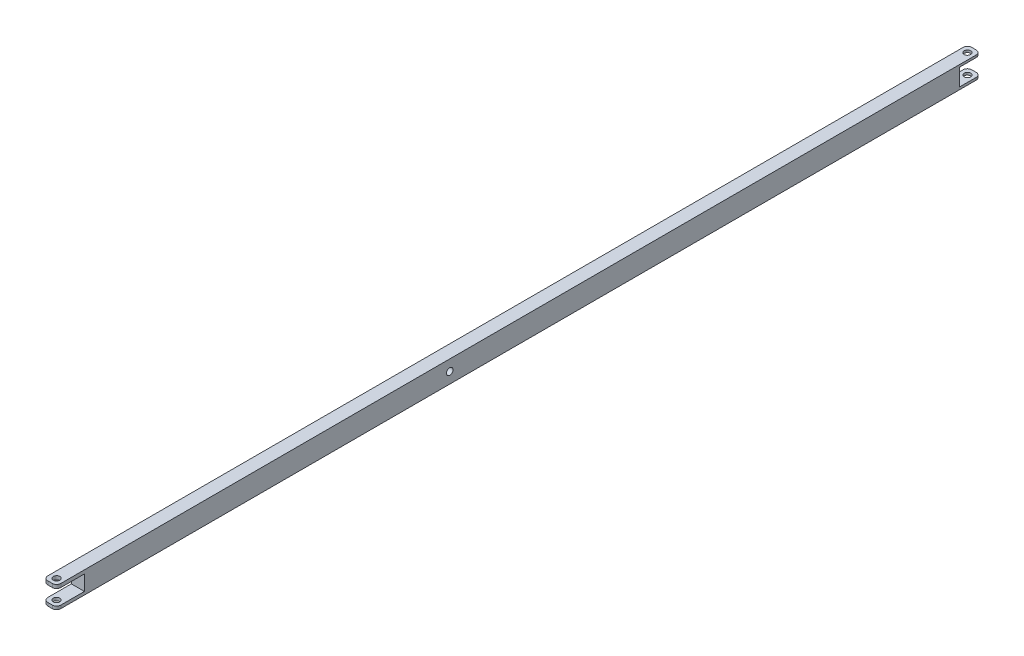
from build123d import *

# Parameters (mm, degrees)
SKETCH1_W           = 7.62
SKETCH1_H           = 12.7
BOSS_EXTRUDE1_DEPTH = 457.2
SKETCH3_R           = 1.905
CUT_EXTRUDE2_DEPTH  = 15
SKETCH4_W           = 16.186958623
SKETCH4_H           = 8.82047947
CUT_EXTRUDE3_DEPTH  = 15
CUT_EXTRUDE4_DEPTH  = 15
FILLET1_R           = 2.5
SKETCH6_W           = 7.62
SKETCH6_H           = 12.7
BOSS_EXTRUDE2_DEPTH = 80
SKETCH7_W           = 12.13309825
SKETCH7_H           = 9.938189712
CUT_EXTRUDE5_DEPTH  = 80
CUT_EXTRUDE6_DEPTH  = 80
FILLET2_R           = 2.5


with BuildPart() as part:
    # Sketch1 → Boss-Extrude1 (new body)
    with BuildSketch(Plane.XY):
        with Locations((3.81, 6.35)):
            Rectangle(SKETCH1_W, SKETCH1_H)
    extrude(amount=BOSS_EXTRUDE1_DEPTH)

    # Sketch3 → Cut-Extrude2 (cut)
    with BuildSketch(Plane(origin=(7.62, 0, 0), x_dir=(0, 0, -1), z_dir=(1, 0, 0))):
        with Locations((-228.6, 6.35)):
            Circle(SKETCH3_R)
    extrude(amount=-CUT_EXTRUDE2_DEPTH, mode=Mode.SUBTRACT)

    # Sketch4 → Cut-Extrude3 (cut)
    with BuildSketch(Plane(origin=(7.62, 0, 0), x_dir=(0, 0, -1), z_dir=(1, 0, 0))):
        with Locations((-449.106520689, 6.226228187)):
            Rectangle(SKETCH4_W, SKETCH4_H)
    extrude(amount=-CUT_EXTRUDE3_DEPTH, mode=Mode.SUBTRACT)

    # Sketch5 → Cut-Extrude4 (cut)
    with BuildSketch(Plane(origin=(0, 12.7, 0), x_dir=(1, 0, 0), z_dir=(0, 1, 0))):
        with BuildLine():
            ThreePointArc((5.157644125, -452.042355875), (2.462355875, -452.042355875), (2.462355875, -454.737644125))
            Line((2.462355875, -454.737644125), (5.157644125, -452.042355875))
        make_face()
        with BuildLine():
            Line((5.157644125, -452.042355875), (2.462355875, -454.737644125))
            ThreePointArc((2.462355875, -454.737644125), (4.539339745, -455.150781904), (5.715856599, -453.39))
            ThreePointArc((5.715856599, -453.39), (5.570781904, -452.660660255), (5.157644125, -452.042355875))
        make_face()
    extrude(amount=-CUT_EXTRUDE4_DEPTH, mode=Mode.SUBTRACT)

    # Fillet1
    fillet1_edges = [part.edges().sort_by_distance(p)[0] for p in [
        (7.62, 0.907994226, 457.2),
        (0, 0.907994226, 457.2),
        (7.62, 11.668233961, 457.2),
        (0, 11.668233961, 457.2),
    ]]
    fillet(fillet1_edges, radius=FILLET1_R)

    # Sketch6 → Boss-Extrude2 (add)
    with BuildSketch(Plane(origin=(0, 0, 0), x_dir=(-1, 0, 0), z_dir=(0, 0, -1))):
        with Locations((-3.81, 6.35)):
            Rectangle(SKETCH6_W, SKETCH6_H)
    extrude(amount=BOSS_EXTRUDE2_DEPTH)

    # Sketch7 → Cut-Extrude5 (cut)
    with BuildSketch(Plane(origin=(7.62, 0, 0), x_dir=(0, 0, -1), z_dir=(1, 0, 0))):
        with Locations((73.933450875, 6.395782886)):
            Rectangle(SKETCH7_W, SKETCH7_H)
    extrude(amount=-CUT_EXTRUDE5_DEPTH, mode=Mode.SUBTRACT)

    # Sketch8 → Cut-Extrude6 (cut)
    with BuildSketch(Plane(origin=(0, 12.7, 0), x_dir=(1, 0, 0), z_dir=(0, 1, 0))):
        with BuildLine():
            ThreePointArc((5.796561175, 76.108438825), (4.620573114, 77.868429334), (2.544522757, 77.455477243))
            Line((2.544522757, 77.455477243), (5.238599594, 74.761400406))
            ThreePointArc((5.238599594, 74.761400406), (5.651551685, 75.379426886), (5.796561175, 76.108438825))
        make_face()
        with BuildLine():
            Line((5.238599594, 74.761400406), (2.544522757, 77.455477243))
            ThreePointArc((2.544522757, 77.455477243), (2.544522757, 74.761400406), (5.238599594, 74.761400406))
        make_face()
    extrude(amount=-CUT_EXTRUDE6_DEPTH, mode=Mode.SUBTRACT)

    # Fillet2
    fillet2_edges = [part.edges().sort_by_distance(p)[0] for p in [
        (0, 0.713344015, -80),
        (7.62, 12.032438871, -80),
        (0, 12.032438871, -80),
        (7.62, 0.713344015, -80),
    ]]
    fillet(fillet2_edges, radius=FILLET2_R)


solid = part.part
